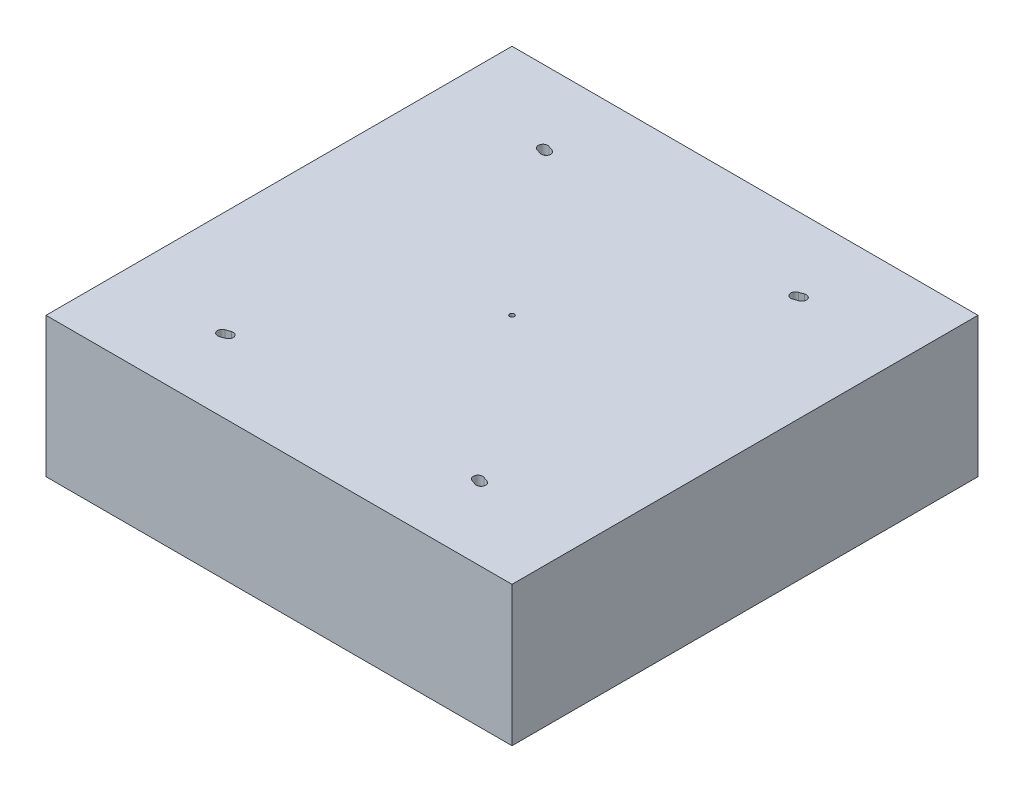
from build123d import *

# Parameters (mm, degrees)
SKETCH1_W                                  = 100
SKETCH1_H                                  = 100
BOSS_EXTRUDE1_DEPTH                        = 15
SKETCH2_R                                  = 0.5
CUT_EXTRUDE1_DEPTH                         = 2
MIRROR1_AT_THE_SECOND_PLANE_COPY_1_SKETC_R = 0.5
MIRROR1_AT_THE_SECOND_PLANE_COPY_1_DEPTH   = 2


with BuildPart() as part:
    # Sketch1 → Boss-Extrude1 (new body, symmetric)
    with BuildSketch(Plane(origin=(0, 0, 0), x_dir=(1, 0, 0), z_dir=(0, 1, 0))):
        Rectangle(SKETCH1_W, SKETCH1_H)
    extrude(amount=BOSS_EXTRUDE1_DEPTH, both=True)

    # Sketch2 → Cut-Extrude1 (cut)
    with BuildSketch(Plane(origin=(0, 15, 0), x_dir=(1, 0, 0), z_dir=(0, 1, 0))):
        Circle(SKETCH2_R)
        with BuildLine():
            Line((-28.090825198, -33.465171233), (-27.090825198, -33.120843619))
            ThreePointArc((-27.090825198, -33.120843619), (-25.819738468, -33.740794041), (-26.439688889, -35.011880771))
            Line((-26.439688889, -35.011880771), (-27.439688889, -35.356208384))
            ThreePointArc((-27.439688889, -35.356208384), (-28.710775619, -34.736257963), (-28.090825198, -33.465171233))
        make_face()
    cut_extrude1 = extrude(amount=-CUT_EXTRUDE1_DEPTH, mode=Mode.SUBTRACT)

    # Mirror1: Cut-Extrude1 across plane
    add(cut_extrude1.mirror(Plane.XY), mode=Mode.SUBTRACT)

    # Mirror1 at the second plane: Cut-Extrude1 across plane
    add(cut_extrude1.mirror(Plane(origin=(0, 0, 0), x_dir=(0, 0, 1), z_dir=(1, 0, 0))), mode=Mode.SUBTRACT)

    # Mirror1 at the second plane copy 1 sketc → Mirror1 at the second plane copy 1 (cut)
    with BuildSketch(Plane(origin=(0, 15, 0), x_dir=(-1, 0, 0), z_dir=(0, 1, 0))):
        Circle(MIRROR1_AT_THE_SECOND_PLANE_COPY_1_SKETC_R)
        with BuildLine():
            Line((-28.090825198, -33.465171233), (-27.090825198, -33.120843619))
            ThreePointArc((-27.090825198, -33.120843619), (-25.819738468, -33.740794041), (-26.439688889, -35.011880771))
            Line((-26.439688889, -35.011880771), (-27.439688889, -35.356208384))
            ThreePointArc((-27.439688889, -35.356208384), (-28.710775619, -34.736257963), (-28.090825198, -33.465171233))
        make_face()
    extrude(amount=-MIRROR1_AT_THE_SECOND_PLANE_COPY_1_DEPTH, mode=Mode.SUBTRACT)


solid = part.part
